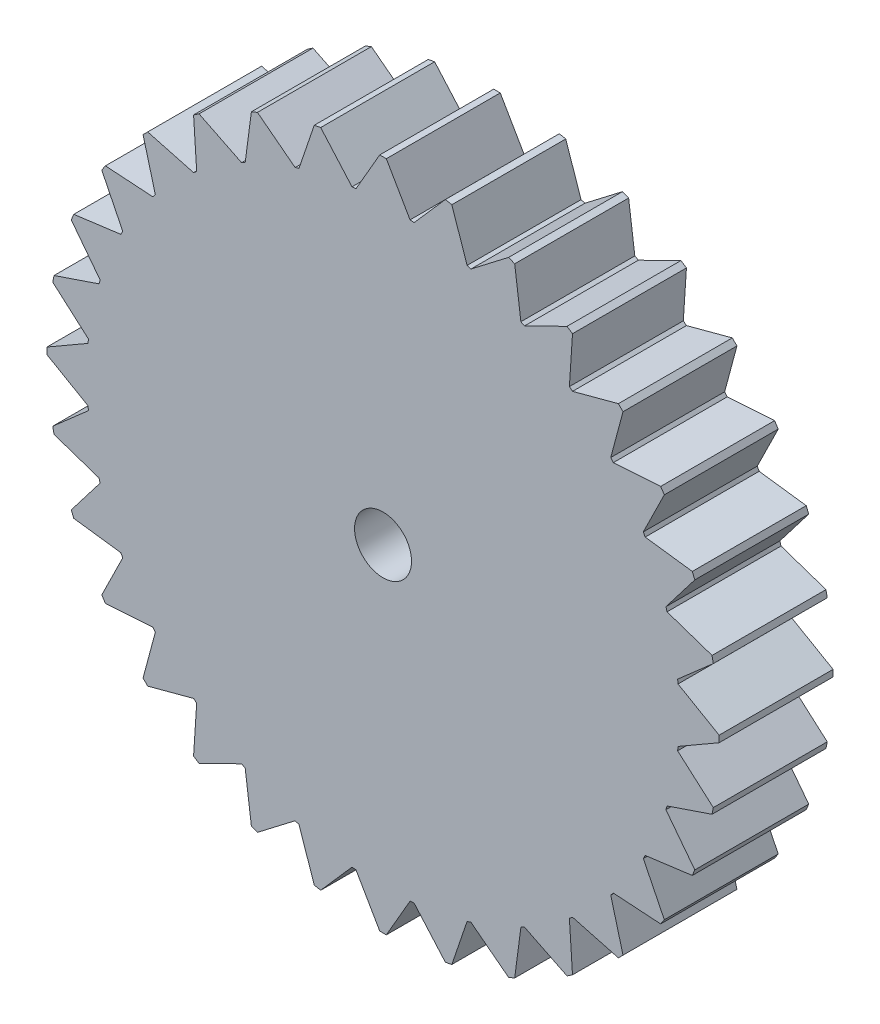
from build123d import *

# Parameters (mm, degrees)
SKETCH1_R           = 2.5
BOSS_EXTRUDE1_DEPTH = 10


with BuildPart() as part:
    # Sketch1 → Boss-Extrude1 (new body)
    with BuildSketch(Plane.XY):
        with BuildLine():
            Line((-28.989483497, 5.472036177), (-25.856829214, 2.724772104))
            ThreePointArc((-25.856829214, 2.724772104), (-25.874802893, 2.548445649), (-25.891574158, 2.372000766))
            Line((-25.891574158, 2.372000766), (-29.5, 0.288675135))
            Line((-29.5, 0.288675135), (-29.5, -0.288675135))
            Line((-29.5, -0.288675135), (-25.891574158, -2.372000766))
            ThreePointArc((-25.891574158, -2.372000766), (-25.874802893, -2.548445649), (-25.856829214, -2.724772104))
            Line((-25.856829214, -2.724772104), (-28.989483497, -5.472036177))
            Line((-28.989483497, -5.472036177), (-28.876848047, -6.038292822))
            Line((-28.876848047, -6.038292822), (-24.931320427, -7.377618976))
            ThreePointArc((-24.931320427, -7.377618976), (-24.880448729, -7.547401609), (-24.828420824, -7.716833509))
            Line((-24.828420824, -7.716833509), (-27.3649174, -11.022460206))
            Line((-27.3649174, -11.022460206), (-27.143975018, -11.555862303))
            Line((-27.143975018, -11.555862303), (-23.012970034, -12.099719427))
            ThreePointArc((-23.012970034, -12.099719427), (-22.929952873, -12.256315157), (-22.845870145, -12.412341331))
            Line((-22.845870145, -12.412341331), (-24.688732875, -16.149297272))
            Line((-24.688732875, -16.149297272), (-24.367974251, -16.629346476))
            Line((-24.367974251, -16.629346476), (-20.210244109, -16.356834445))
            ThreePointArc((-20.210244109, -16.356834445), (-20.098271787, -16.494225388), (-19.985365489, -16.630849836))
            Line((-19.985365489, -16.630849836), (-21.06377419, -20.6555259))
            Line((-21.06377419, -20.6555259), (-20.6555259, -21.06377419))
            Line((-20.6555259, -21.06377419), (-16.630849836, -19.985365489))
            ThreePointArc((-16.630849836, -19.985365489), (-16.494225388, -20.098271787), (-16.356834445, -20.210244109))
            Line((-16.356834445, -20.210244109), (-16.629346476, -24.367974251))
            Line((-16.629346476, -24.367974251), (-16.149297272, -24.688732875))
            Line((-16.149297272, -24.688732875), (-12.412341331, -22.845870145))
            ThreePointArc((-12.412341331, -22.845870145), (-12.256315157, -22.929952873), (-12.099719427, -23.012970034))
            Line((-12.099719427, -23.012970034), (-11.555862303, -27.143975018))
            Line((-11.555862303, -27.143975018), (-11.022460206, -27.3649174))
            Line((-11.022460206, -27.3649174), (-7.716833509, -24.828420824))
            ThreePointArc((-7.716833509, -24.828420824), (-7.547401609, -24.880448729), (-7.377618976, -24.931320427))
            Line((-7.377618976, -24.931320427), (-6.038292822, -28.876848047))
            Line((-6.038292822, -28.876848047), (-5.472036177, -28.989483497))
            Line((-5.472036177, -28.989483497), (-2.724772104, -25.856829214))
            ThreePointArc((-2.724772104, -25.856829214), (-2.548445649, -25.874802893), (-2.372000766, -25.891574158))
            Line((-2.372000766, -25.891574158), (-0.288675135, -29.5))
            Line((-0.288675135, -29.5), (0.288675135, -29.5))
            Line((0.288675135, -29.5), (2.372000766, -25.891574158))
            ThreePointArc((2.372000766, -25.891574158), (2.548445649, -25.874802893), (2.724772104, -25.856829214))
            Line((2.724772104, -25.856829214), (5.472036177, -28.989483497))
            Line((5.472036177, -28.989483497), (6.038292822, -28.876848047))
            Line((6.038292822, -28.876848047), (7.377618976, -24.931320427))
            ThreePointArc((7.377618976, -24.931320427), (7.547401609, -24.880448729), (7.716833509, -24.828420824))
            Line((7.716833509, -24.828420824), (11.022460206, -27.3649174))
            Line((11.022460206, -27.3649174), (11.555862303, -27.143975018))
            Line((11.555862303, -27.143975018), (12.099719427, -23.012970034))
            ThreePointArc((12.099719427, -23.012970034), (12.256315157, -22.929952873), (12.412341331, -22.845870145))
            Line((12.412341331, -22.845870145), (16.149297272, -24.688732875))
            Line((16.149297272, -24.688732875), (16.629346476, -24.367974251))
            Line((16.629346476, -24.367974251), (16.356834445, -20.210244109))
            ThreePointArc((16.356834445, -20.210244109), (16.494225388, -20.098271787), (16.630849836, -19.985365489))
            Line((16.630849836, -19.985365489), (20.6555259, -21.06377419))
            Line((20.6555259, -21.06377419), (21.06377419, -20.6555259))
            Line((21.06377419, -20.6555259), (19.985365489, -16.630849836))
            ThreePointArc((19.985365489, -16.630849836), (20.098271787, -16.494225388), (20.210244109, -16.356834445))
            Line((20.210244109, -16.356834445), (24.367974251, -16.629346476))
            Line((24.367974251, -16.629346476), (24.688732875, -16.149297272))
            Line((24.688732875, -16.149297272), (22.845870145, -12.412341331))
            ThreePointArc((22.845870145, -12.412341331), (22.929952873, -12.256315157), (23.012970034, -12.099719427))
            Line((23.012970034, -12.099719427), (27.143975018, -11.555862303))
            Line((27.143975018, -11.555862303), (27.3649174, -11.022460206))
            Line((27.3649174, -11.022460206), (24.828420824, -7.716833509))
            ThreePointArc((24.828420824, -7.716833509), (24.880448729, -7.547401609), (24.931320427, -7.377618976))
            Line((24.931320427, -7.377618976), (28.876848047, -6.038292822))
            Line((28.876848047, -6.038292822), (28.989483497, -5.472036177))
            Line((28.989483497, -5.472036177), (25.856829214, -2.724772104))
            ThreePointArc((25.856829214, -2.724772104), (25.874802893, -2.548445649), (25.891574158, -2.372000766))
            Line((25.891574158, -2.372000766), (29.5, -0.288675135))
            Line((29.5, -0.288675135), (29.5, 0.288675135))
            Line((29.5, 0.288675135), (25.891574158, 2.372000766))
            ThreePointArc((25.891574158, 2.372000766), (25.874802893, 2.548445649), (25.856829214, 2.724772104))
            Line((25.856829214, 2.724772104), (28.989483497, 5.472036177))
            Line((28.989483497, 5.472036177), (28.876848047, 6.038292822))
            Line((28.876848047, 6.038292822), (24.931320427, 7.377618976))
            ThreePointArc((24.931320427, 7.377618976), (24.880448729, 7.547401609), (24.828420824, 7.716833509))
            Line((24.828420824, 7.716833509), (27.3649174, 11.022460206))
            Line((27.3649174, 11.022460206), (27.143975018, 11.555862303))
            Line((27.143975018, 11.555862303), (23.012970034, 12.099719427))
            ThreePointArc((23.012970034, 12.099719427), (22.929952873, 12.256315157), (22.845870145, 12.412341331))
            Line((22.845870145, 12.412341331), (24.688732875, 16.149297272))
            Line((24.688732875, 16.149297272), (24.367974251, 16.629346476))
            Line((24.367974251, 16.629346476), (20.210244109, 16.356834445))
            ThreePointArc((20.210244109, 16.356834445), (20.098271787, 16.494225388), (19.985365489, 16.630849836))
            Line((19.985365489, 16.630849836), (21.06377419, 20.6555259))
            Line((21.06377419, 20.6555259), (20.6555259, 21.06377419))
            Line((20.6555259, 21.06377419), (16.630849836, 19.985365489))
            ThreePointArc((16.630849836, 19.985365489), (16.494225388, 20.098271787), (16.356834445, 20.210244109))
            Line((16.356834445, 20.210244109), (16.629346476, 24.367974251))
            Line((16.629346476, 24.367974251), (16.149297272, 24.688732875))
            Line((16.149297272, 24.688732875), (12.412341331, 22.845870145))
            ThreePointArc((12.412341331, 22.845870145), (12.256315157, 22.929952873), (12.099719427, 23.012970034))
            Line((12.099719427, 23.012970034), (11.555862303, 27.143975018))
            Line((11.555862303, 27.143975018), (11.022460206, 27.3649174))
            Line((11.022460206, 27.3649174), (7.716833509, 24.828420824))
            ThreePointArc((7.716833509, 24.828420824), (7.547401609, 24.880448729), (7.377618976, 24.931320427))
            Line((7.377618976, 24.931320427), (6.038292822, 28.876848047))
            Line((6.038292822, 28.876848047), (5.472036177, 28.989483497))
            Line((5.472036177, 28.989483497), (2.724772104, 25.856829214))
            ThreePointArc((2.724772104, 25.856829214), (2.548445649, 25.874802893), (2.372000766, 25.891574158))
            Line((2.372000766, 25.891574158), (0.288675135, 29.5))
            Line((0.288675135, 29.5), (-0.288675135, 29.5))
            Line((-0.288675135, 29.5), (-2.372000766, 25.891574158))
            ThreePointArc((-2.372000766, 25.891574158), (-2.548445649, 25.874802893), (-2.724772104, 25.856829214))
            Line((-2.724772104, 25.856829214), (-5.472036177, 28.989483497))
            Line((-5.472036177, 28.989483497), (-6.038292822, 28.876848047))
            Line((-6.038292822, 28.876848047), (-7.377618976, 24.931320427))
            ThreePointArc((-7.377618976, 24.931320427), (-7.547401609, 24.880448729), (-7.716833509, 24.828420824))
            Line((-7.716833509, 24.828420824), (-11.022460206, 27.3649174))
            Line((-11.022460206, 27.3649174), (-11.555862303, 27.143975018))
            Line((-11.555862303, 27.143975018), (-12.099719427, 23.012970034))
            ThreePointArc((-12.099719427, 23.012970034), (-12.256315157, 22.929952873), (-12.412341331, 22.845870145))
            Line((-12.412341331, 22.845870145), (-16.149297272, 24.688732875))
            Line((-16.149297272, 24.688732875), (-16.629346476, 24.367974251))
            Line((-16.629346476, 24.367974251), (-16.356834445, 20.210244109))
            ThreePointArc((-16.356834445, 20.210244109), (-16.494225388, 20.098271787), (-16.630849836, 19.985365489))
            Line((-16.630849836, 19.985365489), (-20.6555259, 21.06377419))
            Line((-20.6555259, 21.06377419), (-21.06377419, 20.6555259))
            Line((-21.06377419, 20.6555259), (-19.985365489, 16.630849836))
            ThreePointArc((-19.985365489, 16.630849836), (-20.098271787, 16.494225388), (-20.210244109, 16.356834445))
            Line((-20.210244109, 16.356834445), (-24.367974251, 16.629346476))
            Line((-24.367974251, 16.629346476), (-24.688732875, 16.149297272))
            Line((-24.688732875, 16.149297272), (-22.845870145, 12.412341331))
            ThreePointArc((-22.845870145, 12.412341331), (-22.929952873, 12.256315157), (-23.012970034, 12.099719427))
            Line((-23.012970034, 12.099719427), (-27.143975018, 11.555862303))
            Line((-27.143975018, 11.555862303), (-27.3649174, 11.022460206))
            Line((-27.3649174, 11.022460206), (-24.828420824, 7.716833509))
            ThreePointArc((-24.828420824, 7.716833509), (-24.880448729, 7.547401609), (-24.931320427, 7.377618976))
            Line((-24.931320427, 7.377618976), (-28.876848047, 6.038292822))
            Line((-28.876848047, 6.038292822), (-28.989483497, 5.472036177))
        make_face()
        Circle(SKETCH1_R, mode=Mode.SUBTRACT)
    extrude(amount=BOSS_EXTRUDE1_DEPTH)


solid = part.part
